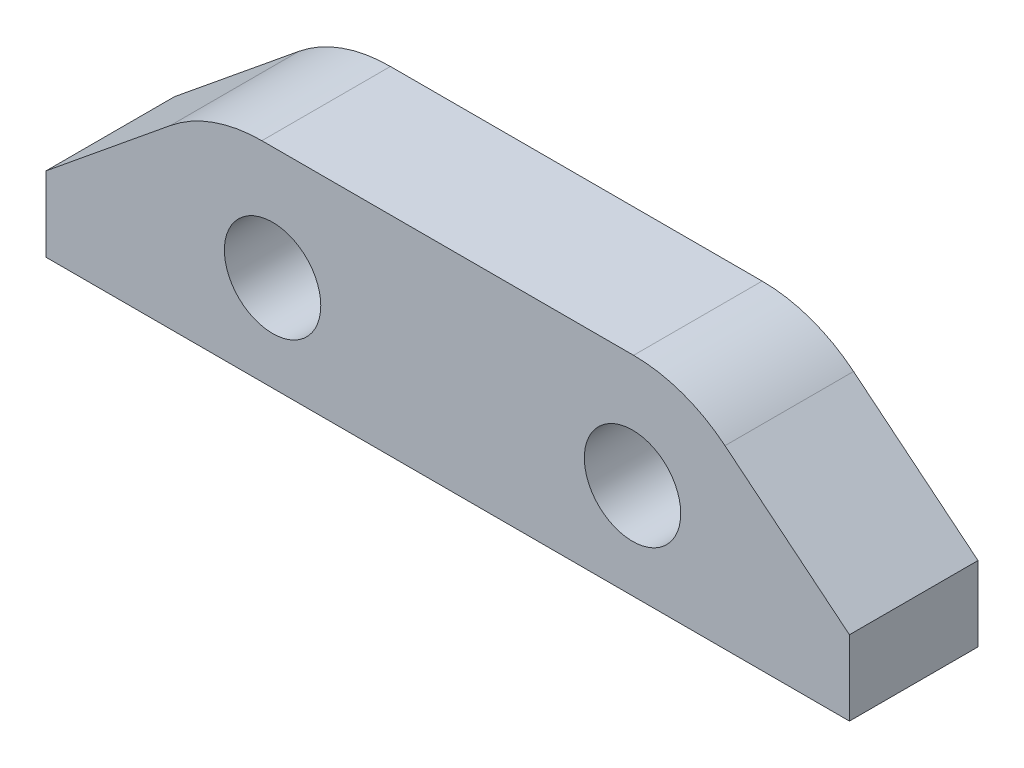
from build123d import *

# Parameters (mm, degrees)
SKETCH1_R           = 1.5
BOSS_EXTRUDE1_DEPTH = 4


with BuildPart() as part:
    # Sketch1 → Boss-Extrude1 (new body)
    with BuildSketch(Plane.XY):
        with BuildLine():
            Line((18.283368275, 6.499999319), (6.716637678, 6.499999319))
            ThreePointArc((6.716637678, 6.499999319), (5.206858361, 6.239169805), (3.872099046, 5.486917725))
            Line((3.872099046, 5.486917725), (2.976e-06, 2.328161032))
            Line((2.976e-06, 2.328161032), (2.976e-06, -6.81e-07))
            Line((2.976e-06, -6.81e-07), (25.000002976, -6.81e-07))
            Line((25.000002976, -6.81e-07), (25.000002976, 2.328161032))
            Line((25.000002976, 2.328161032), (21.127906906, 5.486917725))
            ThreePointArc((21.127906906, 5.486917725), (19.793147591, 6.239169805), (18.283368275, 6.499999319))
        make_face()
        with Locations((7.050002976, 2.969999319)):
            Circle(SKETCH1_R, mode=Mode.SUBTRACT)
        with Locations((18.250002976, 2.969999319)):
            Circle(SKETCH1_R, mode=Mode.SUBTRACT)
    extrude(amount=BOSS_EXTRUDE1_DEPTH)


solid = part.part
